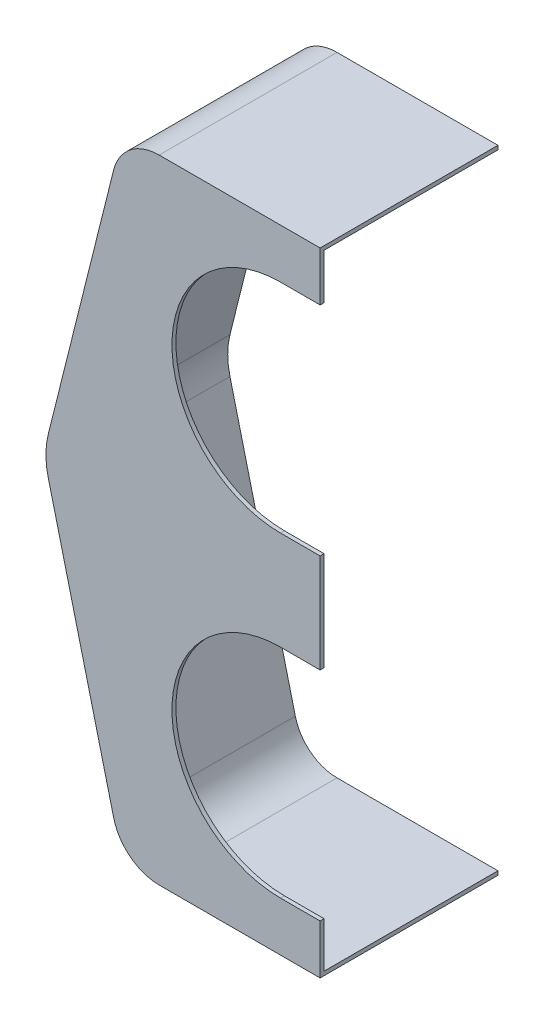
from build123d import *

# Parameters (mm, degrees)
SKETCH1_W           = 114.3
SKETCH1_H           = 203.2
BOSS_EXTRUDE1_DEPTH = 88.9
CUT_EXTRUDE1_DEPTH  = 115.3
FILLET1_R           = 25.24
FILLET2_R           = 15.08
CUT_EXTRUDE2_DEPTH  = 115.3
LPATTERN1_COUNT     = 2
LPATTERN1_PITCH     = 101.6
SHELL5_T            = -1.27
SKETCH9_R           = 3
BOSS_EXTRUDE2_DEPTH = 8.89
SKETCH10_W          = 88.123203502
SKETCH10_H          = 57.15
CUT_EXTRUDE3_DEPTH  = 204.2


with BuildPart() as part:
    # Sketch1 → Boss-Extrude1 (new body)
    with BuildSketch(Plane(origin=(0, 0, 0), x_dir=(0, 0, -1), z_dir=(1, 0, 0))):
        with Locations((57.15, -101.6)):
            Rectangle(SKETCH1_W, SKETCH1_H)
    extrude(amount=-BOSS_EXTRUDE1_DEPTH)

    # Sketch4 → Cut-Extrude1 (cut, through all)
    with BuildSketch(Plane(origin=(0, 0, -114.3), x_dir=(-1, 0, 0), z_dir=(0, 0, -1))):
        Polygon((88.9, 0), (63.5, 0), (88.9, -101.6), align=None)
        Polygon((88.9, -203.2), (88.9, -101.6), (63.5, -203.2), align=None)
    extrude(amount=-CUT_EXTRUDE1_DEPTH, mode=Mode.SUBTRACT)

    # Fillet1
    fillet1_edges = [part.edges().sort_by_distance(p)[0] for p in [
        (-88.9, -101.6, -57.15),
    ]]
    fillet(fillet1_edges, radius=FILLET1_R)

    # Fillet2
    fillet2_edges = [part.edges().sort_by_distance(p)[0] for p in [
        (-63.5, 0, -57.15),
        (-63.5, -203.2, -57.15),
    ]]
    fillet(fillet2_edges, radius=FILLET2_R)

    # Sketch5 → Cut-Extrude2 (cut, through all)
    with BuildSketch(Plane.XY):
        with BuildLine():
            Line((-12.7, -187.325), (0, -187.325))
            Line((0, -187.325), (0, -117.475))
            Line((0, -117.475), (-12.7, -117.475))
            ThreePointArc((-12.7, -117.475), (-47.625, -152.4), (-12.7, -187.325))
        make_face()
    cut_extrude2 = extrude(amount=-CUT_EXTRUDE2_DEPTH, mode=Mode.SUBTRACT)

    # LPattern1: Cut-Extrude2 ×2
    with Locations(*[(0, i * LPATTERN1_PITCH, 0) for i in range(1, LPATTERN1_COUNT)]):
        add(cut_extrude2, mode=Mode.SUBTRACT)

    # Shell5
    shell5_openings = [part.faces().sort_by_distance(p)[0] for p in [
        (0, -195.2625, -57.15),
        (0, -101.6, -57.15),
        (-30.1625, -152.4, -57.15),
        (-6.35, -117.475, -57.15),
        (-6.35, -187.325, -57.15),
        (0, -7.9375, -57.15),
        (-30.1625, -50.8, -57.15),
        (-6.35, -15.875, -57.15),
        (-6.35, -85.725, -57.15),
    ]]
    offset(amount=SHELL5_T, openings=shell5_openings, kind=Kind.INTERSECTION)

    # Sketch9 → Boss-Extrude2 (add)
    with BuildSketch(Plane.XY.offset(-113.03)):
        with Locations((-12.7, -101.6)):
            Circle(SKETCH9_R)
    boss_extrude2 = extrude(amount=BOSS_EXTRUDE2_DEPTH)

    # Mirror1: Boss-Extrude2 across plane
    add(boss_extrude2.mirror(Plane.XY.offset(-57.15)))

    # Sketch10 → Cut-Extrude3 (cut, through all)
    with BuildSketch(Plane(origin=(0, 0, 0), x_dir=(1, 0, 0), z_dir=(0, 1, 0))):
        with Locations((-44.061601751, 85.725)):
            Rectangle(SKETCH10_W, SKETCH10_H)
    extrude(amount=-CUT_EXTRUDE3_DEPTH, mode=Mode.SUBTRACT)


solid = part.part
